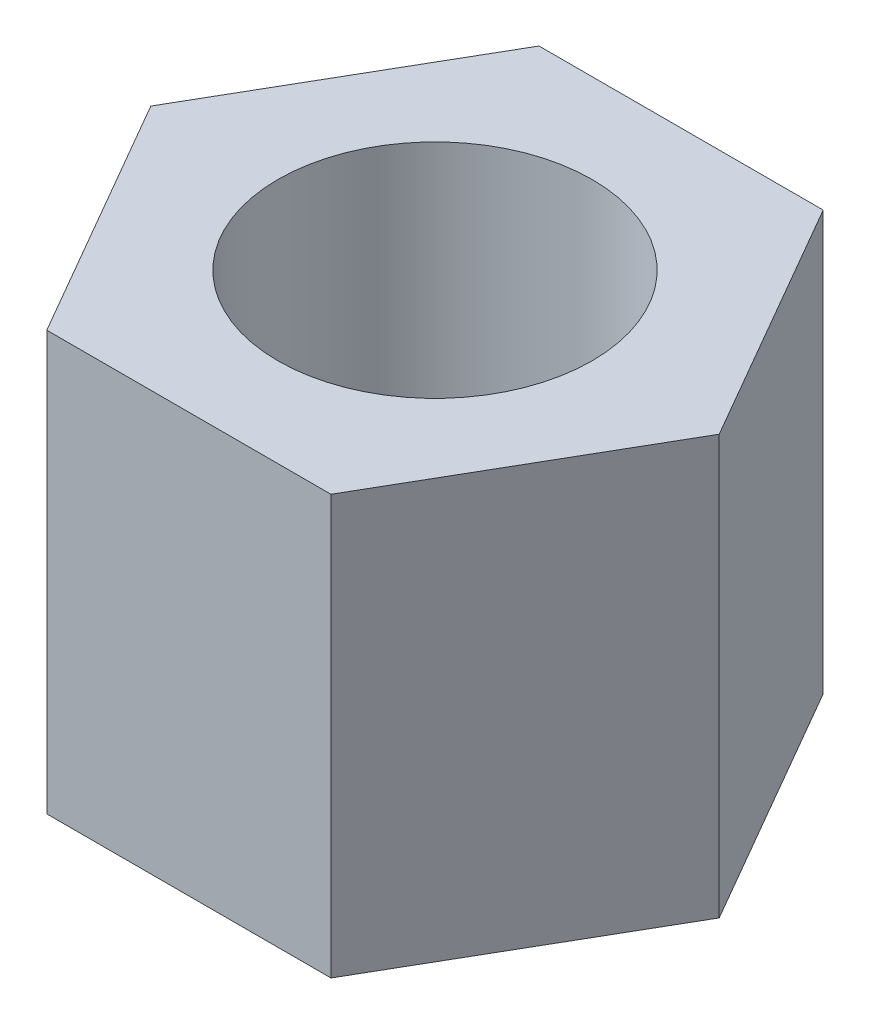
from build123d import *

# Parameters (mm, degrees)
SKETCH_1_R      = 1.5
EXTRUDE_1_DEPTH = 4


with BuildPart() as part:
    # 草图1 → 凸台-拉伸1 (new body)
    with BuildSketch(Plane(origin=(0, 0, 0), x_dir=(1, 0, 0), z_dir=(0, 1, 0))):
        Polygon((-1.356773133, 2.35), (1.356773133, 2.35), (2.713546265, 0), (1.356773133, -2.35), (-1.356773133, -2.35), (-2.713546265, 0), align=None)
        Circle(SKETCH_1_R, mode=Mode.SUBTRACT)
    extrude(amount=EXTRUDE_1_DEPTH)


solid = part.part
